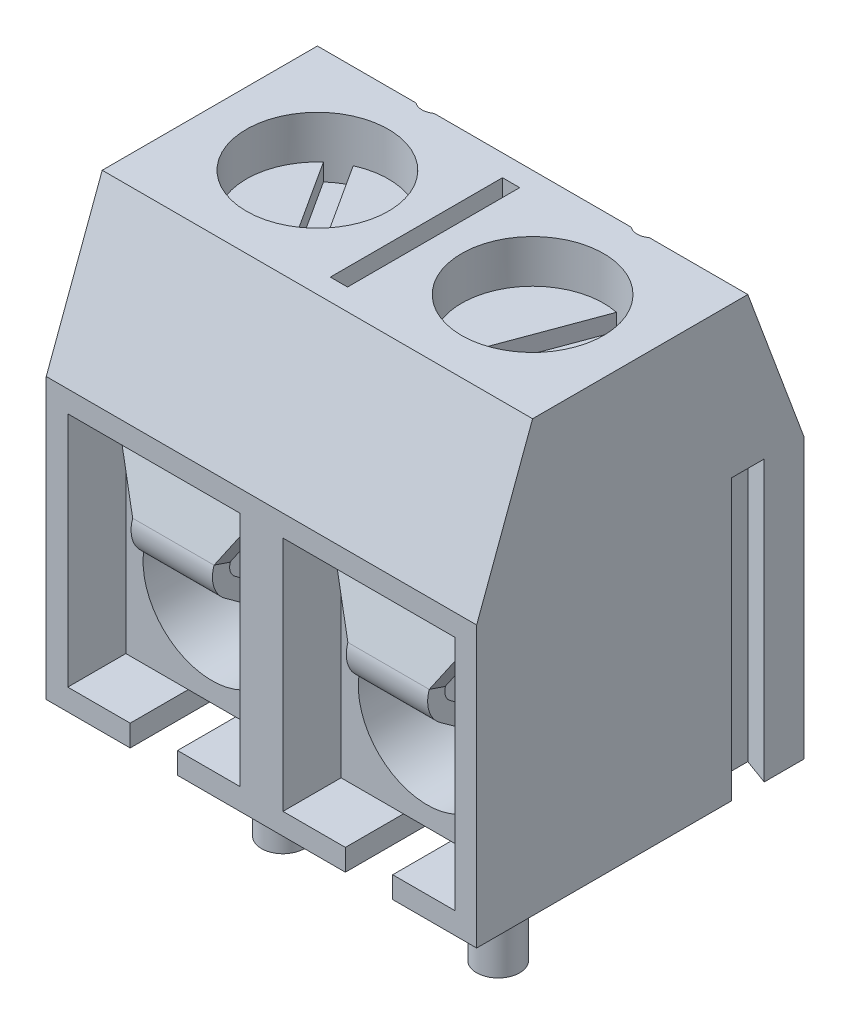
from build123d import *

# Parameters (mm, degrees)
SKETCH1_W               = 10
SKETCH1_H               = 7.6
EXTRUDE1_DEPTH          = 10
SKETCH2_OUTSIDE_W       = 12.81
SKETCH2_OUTSIDE_H       = 15.21
CUT_EXTRUDE1_DEPTH      = 6
CUT_EXTRUDE1_DEPTH_BACK = 6
SKETCH3_R               = 1.65
SKETCH3_R_2             = 0.35
SKETCH3_W               = 0.4
SKETCH3_H               = 4
CUT_EXTRUDE2_DEPTH      = 4
SKETCH4_W               = 4
SKETCH4_H               = 5.5
CUT_EXTRUDE3_DEPTH      = 5.6
SKETCH5_W               = 4
SKETCH5_H               = 5.1
EXTRUDE2_DEPTH          = 4.25
SKETCH6_R               = 1.6
CUT_EXTRUDE4_DEPTH      = 4.25
EXTRUDE3_DEPTH          = 6.5
CUT_EXTRUDE5_DEPTH      = 6.5
SKETCH10_W              = 1.1
SKETCH10_H              = 0.5
CUT_EXTRUDE6_DEPTH      = 3.6
SKETCH11_R              = 0.5
EXTRUDE4_DEPTH          = 3.5
SKETCH12_R              = 1.65
EXTRUDE5_DEPTH          = 3
CUT_EXTRUDE7_DEPTH      = 0.4
EXTRUDE6_DEPTH          = 0.945
EXTRUDE9_DEPTH          = 0.39
LPATTERN1_COUNT         = 2
LPATTERN1_PITCH         = 5
FILLET1_R               = 0.3
FILLET2_R               = 0.7


with BuildPart() as part:
    # Sketch1 → Extrude1 (new body)
    with BuildSketch(Plane(origin=(0, 0, 0), x_dir=(1, 0, 0), z_dir=(0, 1, 0))):
        Rectangle(SKETCH1_W, SKETCH1_H)
    extrude(amount=EXTRUDE1_DEPTH)

    # Sketch2 outside → Cut-Extrude1 (cut, two sides)
    with BuildSketch(Plane(origin=(0, 0, 0), x_dir=(0, 0, -1), z_dir=(1, 0, 0))) as cut_extrude1_sk:
        with Locations((0, 5)):
            Rectangle(SKETCH2_OUTSIDE_W, SKETCH2_OUTSIDE_H)
        Polygon((2.5, 10), (3.8, 6.5), (3.8, 0), (-3.8, 0), (-3.8, 6.5), (-2.5, 10), align=None, mode=Mode.SUBTRACT)
    extrude(amount=CUT_EXTRUDE1_DEPTH, mode=Mode.SUBTRACT)
    extrude(cut_extrude1_sk.sketch, amount=-CUT_EXTRUDE1_DEPTH_BACK, mode=Mode.SUBTRACT)

    # Sketch3 → Cut-Extrude2 (cut)
    with BuildSketch(Plane(origin=(0, 10, 0), x_dir=(-1, 0, 0), z_dir=(0, 1, 0))):
        with Locations((2.5, 0)):
            Circle(SKETCH3_R)
        with Locations((-2.5, 0)):
            Circle(SKETCH3_R)
        with Locations((2.5, -2.78)):
            Circle(SKETCH3_R_2)
        with Locations((-2.5, -2.78)):
            Circle(SKETCH3_R_2)
        Rectangle(SKETCH3_W, SKETCH3_H)
    extrude(amount=-CUT_EXTRUDE2_DEPTH, mode=Mode.SUBTRACT)

    # Sketch4 → Cut-Extrude3 (cut)
    with BuildSketch(Plane.XY.offset(3.8)):
        with Locations((-2.5, 3.25)):
            Rectangle(SKETCH4_W, SKETCH4_H)
        with Locations((2.5, 3.25)):
            Rectangle(SKETCH4_W, SKETCH4_H)
    extrude(amount=-CUT_EXTRUDE3_DEPTH, mode=Mode.SUBTRACT)

    # Sketch5 → Extrude2 (add)
    with BuildSketch(Plane.XY.offset(-1.8)):
        with Locations((-2.5, 3.05)):
            Rectangle(SKETCH5_W, SKETCH5_H)
        with Locations((2.5, 3.05)):
            Rectangle(SKETCH5_W, SKETCH5_H)
    extrude(amount=EXTRUDE2_DEPTH)

    # Sketch6 → Cut-Extrude4 (cut)
    with BuildSketch(Plane.XY.offset(2.45)):
        with Locations((-2.5, 2.554263468)):
            Circle(SKETCH6_R)
        with Locations((2.5, 2.554263468)):
            Circle(SKETCH6_R)
    extrude(amount=-CUT_EXTRUDE4_DEPTH, mode=Mode.SUBTRACT)

    # Sketch7 → Extrude3 (add)
    with BuildSketch(Plane(origin=(0, 0, 0), x_dir=(1, 0, 0), z_dir=(0, 1, 0))):
        Polygon((-5.6, 3.1), (-5, 2.881617859), (-5, 2.118382141), (-5.6, 1.9), align=None)
    extrude(amount=EXTRUDE3_DEPTH)

    # Sketch9 → Cut-Extrude5 (cut)
    with BuildSketch(Plane(origin=(0, 0, 0), x_dir=(1, 0, 0), z_dir=(0, 1, 0))):
        Polygon((5, 2.881617859), (4.4, 3.1), (4.4, 1.9), (5, 2.118382141), align=None)
    extrude(amount=CUT_EXTRUDE5_DEPTH, mode=Mode.SUBTRACT)

    # Sketch10 → Cut-Extrude6 (cut)
    with BuildSketch(Plane.XY.offset(3.8)):
        with Locations((-2.5, 0.25)):
            Rectangle(SKETCH10_W, SKETCH10_H)
        with Locations((2.5, 0.25)):
            Rectangle(SKETCH10_W, SKETCH10_H)
    extrude(amount=-CUT_EXTRUDE6_DEPTH, mode=Mode.SUBTRACT)

    # Sketch11 → Extrude4 (add)
    with BuildSketch(Plane.XZ.offset(-0.5)):
        with Locations((-2.5, 0.8)):
            Circle(SKETCH11_R)
        with Locations((2.5, 0.8)):
            Circle(SKETCH11_R)
    extrude(amount=EXTRUDE4_DEPTH)

    # Sketch12 → Extrude5 (add)
    with BuildSketch(Plane.XZ.offset(-6)):
        with Locations((2.5, 0)):
            Circle(SKETCH12_R)
        with Locations((-2.5, 0)):
            Circle(SKETCH12_R)
    extrude(amount=-EXTRUDE5_DEPTH)

    # Sketch13 → Cut-Extrude7 (cut)
    with BuildSketch(Plane(origin=(0, 9, 0), x_dir=(-1, 0, 0), z_dir=(0, 1, 0))):
        with BuildLine():
            Line((3.594307251, -1.234905519), (1.825829895, 1.505986278))
            ThreePointArc((1.825829895, 1.505986278), (1.605433494, 1.386452583), (1.405692749, 1.234905519))
            Line((1.405692749, 1.234905519), (3.174170105, -1.505986278))
            ThreePointArc((3.174170105, -1.505986278), (3.394566506, -1.386452583), (3.594307251, -1.234905519))
        make_face()
        with BuildLine():
            Line((-2.83217089, -1.616218581), (-1.698971441, 1.44251629))
            ThreePointArc((-1.698971441, 1.44251629), (-1.926782442, 1.54723031), (-2.16782911, 1.616218581))
            Line((-2.16782911, 1.616218581), (-3.301028559, -1.44251629))
            ThreePointArc((-3.301028559, -1.44251629), (-3.073217558, -1.54723031), (-2.83217089, -1.616218581))
        make_face()
    extrude(amount=-CUT_EXTRUDE7_DEPTH, mode=Mode.SUBTRACT)

    # Sketch14 → Extrude6 (add, symmetric)
    with BuildSketch(Plane.ZY.offset(2.5)):
        Polygon((2.45, 5.6), (3.03887637, 3.861674443), (0.167170254, 1.787608865), (-0.546359637, 2.097431054), (-0.705673534, 1.730526322), (0.216750724, 1.33), (3.512480259, 3.710312924), (2.736824279, 6), (-1.8, 6), (-1.8, 5.6), align=None)
    extrude6 = extrude(amount=EXTRUDE6_DEPTH, both=True)

    # Sketch15 → Extrude9 (add)
    with BuildSketch(Plane(origin=(0, 1.449355072, 4.278403908), x_dir=(1, 0, 0), z_dir=(0, 0.320850379, 0.947129893))):
        Polygon((-1.555, 4.8), (-1.555, 2.903968921), (-0.51, 4.8), align=None)
        Polygon((-3.445, 4.8), (-3.445, 2.903968921), (-4.49, 4.8), align=None)
    extrude9 = extrude(amount=-EXTRUDE9_DEPTH)

    # LPattern1: Extrude6, Extrude9 ×2
    with Locations(*[(i * LPATTERN1_PITCH, 0, 0) for i in range(1, LPATTERN1_COUNT)]):
        add(extrude6)
        add(extrude9)

    # Fillet1
    fillet1_edges = [part.edges().sort_by_distance(p)[0] for p in [
        (-2.5, 3.861674443, 3.03887637),
        (-2.5, 1.787608865, 0.167170254),
        (2.5, 3.861674443, 3.03887637),
        (2.5, 1.787608865, 0.167170254),
    ]]
    fillet(fillet1_edges, radius=FILLET1_R)

    # Fillet2
    fillet2_edges = [part.edges().sort_by_distance(p)[0] for p in [
        (-2.5, 3.710312924, 3.512480259),
        (-2.5, 1.33, 0.216750724),
        (2.5, 1.33, 0.216750724),
        (2.5, 3.710312924, 3.512480259),
    ]]
    fillet(fillet2_edges, radius=FILLET2_R)


solid = part.part
